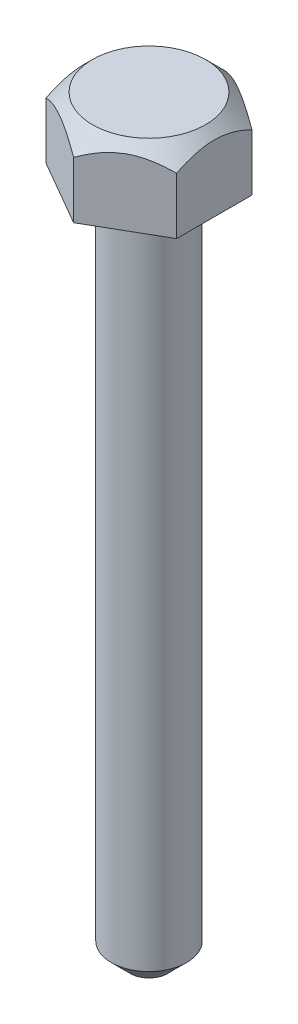
from build123d import *

# Parameters (mm, degrees)
CUT_EXTRUDE1_REACH = 33.75


with BuildPart() as part:
    # Sketch1 → Revolve1 (revolve)
    with BuildSketch(Plane.XY):
        Polygon((0, 31.75), (-2.38125, 31.75), (-3.175, 30.95625), (-3.175, 28.575), (-1.5875, 28.575), (-1.5875, 0.79375), (-0.79375, 0), (0, 0), align=None)
    revolve(axis=Axis((0, 0, 0), (0, 1, 0)))

    # Sketch2 → Cut-Extrude1 (cut, up to next)
    with BuildSketch(Plane(origin=(0, 31.75, 0), x_dir=(1, 0, 0), z_dir=(0, 1, 0)), mode=Mode.PRIVATE) as cut_extrude1_sk1:
        with BuildLine():
            Line((-2.749630657, 1.5875), (0, 3.175))
            ThreePointArc((0, 3.175), (-1.5875, 2.749630657), (-2.749630657, 1.5875))
        make_face()
    cut_extrude1_tool1 = extrude(cut_extrude1_sk1.sketch, amount=-CUT_EXTRUDE1_REACH, mode=Mode.PRIVATE) & part.part
    add(cut_extrude1_tool1.solids().sort_by_distance((-1.460397, 31.75, -2.529482))[0], mode=Mode.SUBTRACT)
    # Sketch2 → Cut-Extrude1 (cut, up to next)
    with BuildSketch(Plane(origin=(0, 31.75, 0), x_dir=(1, 0, 0), z_dir=(0, 1, 0)), mode=Mode.PRIVATE) as cut_extrude1_sk2:
        with BuildLine():
            ThreePointArc((2.749630657, 1.5875), (1.5875, 2.749630657), (0, 3.175))
            Line((0, 3.175), (2.749630657, 1.5875))
        make_face()
    cut_extrude1_tool2 = extrude(cut_extrude1_sk2.sketch, amount=-CUT_EXTRUDE1_REACH, mode=Mode.PRIVATE) & part.part
    add(cut_extrude1_tool2.solids().sort_by_distance((1.460397, 31.75, -2.529482))[0], mode=Mode.SUBTRACT)
    # Sketch2 → Cut-Extrude1 (cut, up to next)
    with BuildSketch(Plane(origin=(0, 31.75, 0), x_dir=(1, 0, 0), z_dir=(0, 1, 0)), mode=Mode.PRIVATE) as cut_extrude1_sk3:
        with BuildLine():
            ThreePointArc((3.175, 0), (3.066814498, 0.821750468), (2.749630657, 1.5875))
            Line((2.749630657, 1.5875), (2.749630657, -1.5875))
            ThreePointArc((2.749630657, -1.5875), (3.066814498, -0.821750468), (3.175, 0))
        make_face()
    cut_extrude1_tool3 = extrude(cut_extrude1_sk3.sketch, amount=-CUT_EXTRUDE1_REACH, mode=Mode.PRIVATE) & part.part
    add(cut_extrude1_tool3.solids().sort_by_distance((2.920795, 31.75, 0))[0], mode=Mode.SUBTRACT)
    # Sketch2 → Cut-Extrude1 (cut, up to next)
    with BuildSketch(Plane(origin=(0, 31.75, 0), x_dir=(1, 0, 0), z_dir=(0, 1, 0)), mode=Mode.PRIVATE) as cut_extrude1_sk4:
        with BuildLine():
            ThreePointArc((0, -3.175), (1.5875, -2.749630657), (2.749630657, -1.5875))
            Line((2.749630657, -1.5875), (0, -3.175))
        make_face()
    cut_extrude1_tool4 = extrude(cut_extrude1_sk4.sketch, amount=-CUT_EXTRUDE1_REACH, mode=Mode.PRIVATE) & part.part
    add(cut_extrude1_tool4.solids().sort_by_distance((1.460397, 31.75, 2.529482))[0], mode=Mode.SUBTRACT)
    # Sketch2 → Cut-Extrude1 (cut, up to next)
    with BuildSketch(Plane(origin=(0, 31.75, 0), x_dir=(1, 0, 0), z_dir=(0, 1, 0)), mode=Mode.PRIVATE) as cut_extrude1_sk5:
        with BuildLine():
            Line((0, -3.175), (-2.749630657, -1.5875))
            ThreePointArc((-2.749630657, -1.5875), (-1.5875, -2.749630657), (0, -3.175))
        make_face()
    cut_extrude1_tool5 = extrude(cut_extrude1_sk5.sketch, amount=-CUT_EXTRUDE1_REACH, mode=Mode.PRIVATE) & part.part
    add(cut_extrude1_tool5.solids().sort_by_distance((-1.460397, 31.75, 2.529482))[0], mode=Mode.SUBTRACT)
    # Sketch2 → Cut-Extrude1 (cut, up to next)
    with BuildSketch(Plane(origin=(0, 31.75, 0), x_dir=(1, 0, 0), z_dir=(0, 1, 0)), mode=Mode.PRIVATE) as cut_extrude1_sk6:
        with BuildLine():
            Line((-2.749630657, -1.5875), (-2.749630657, 1.5875))
            ThreePointArc((-2.749630657, 1.5875), (-3.175, 0), (-2.749630657, -1.5875))
        make_face()
    cut_extrude1_tool6 = extrude(cut_extrude1_sk6.sketch, amount=-CUT_EXTRUDE1_REACH, mode=Mode.PRIVATE) & part.part
    add(cut_extrude1_tool6.solids().sort_by_distance((-2.920795, 31.75, 0))[0], mode=Mode.SUBTRACT)


solid = part.part
